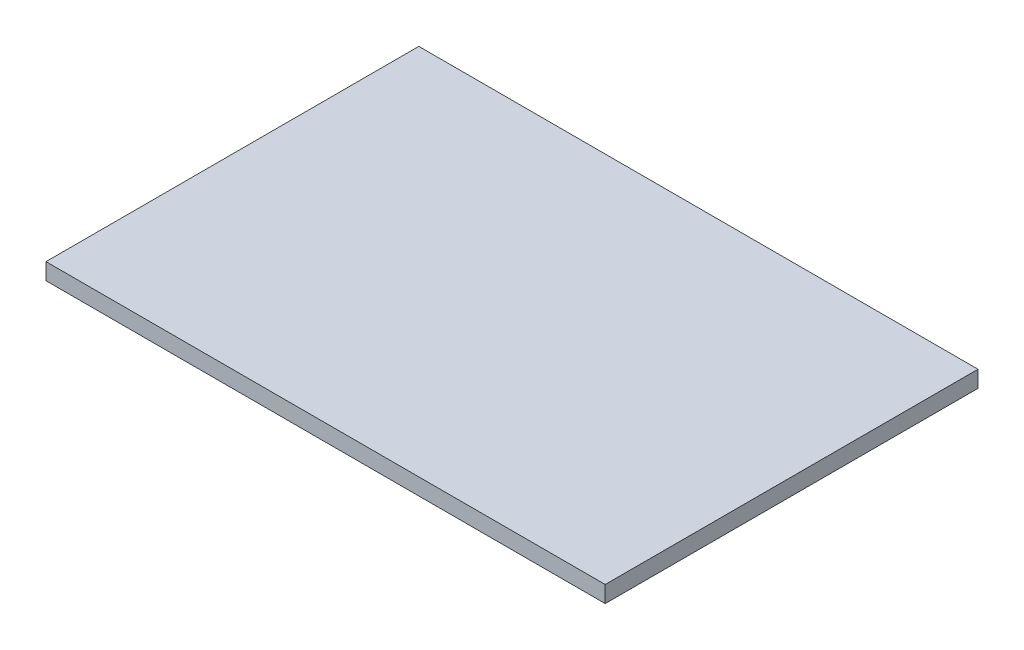
from build123d import *

# Parameters (mm, degrees)
SKETCH1_W           = 85.725
SKETCH1_H           = 57.15
BOSS_EXTRUDE1_DEPTH = 2.54


with BuildPart() as part:
    # Sketch1 → Boss-Extrude1 (new body)
    with BuildSketch(Plane(origin=(0, 0, 0), x_dir=(1, 0, 0), z_dir=(0, 1, 0))):
        Rectangle(SKETCH1_W, SKETCH1_H)
    extrude(amount=BOSS_EXTRUDE1_DEPTH)


solid = part.part
